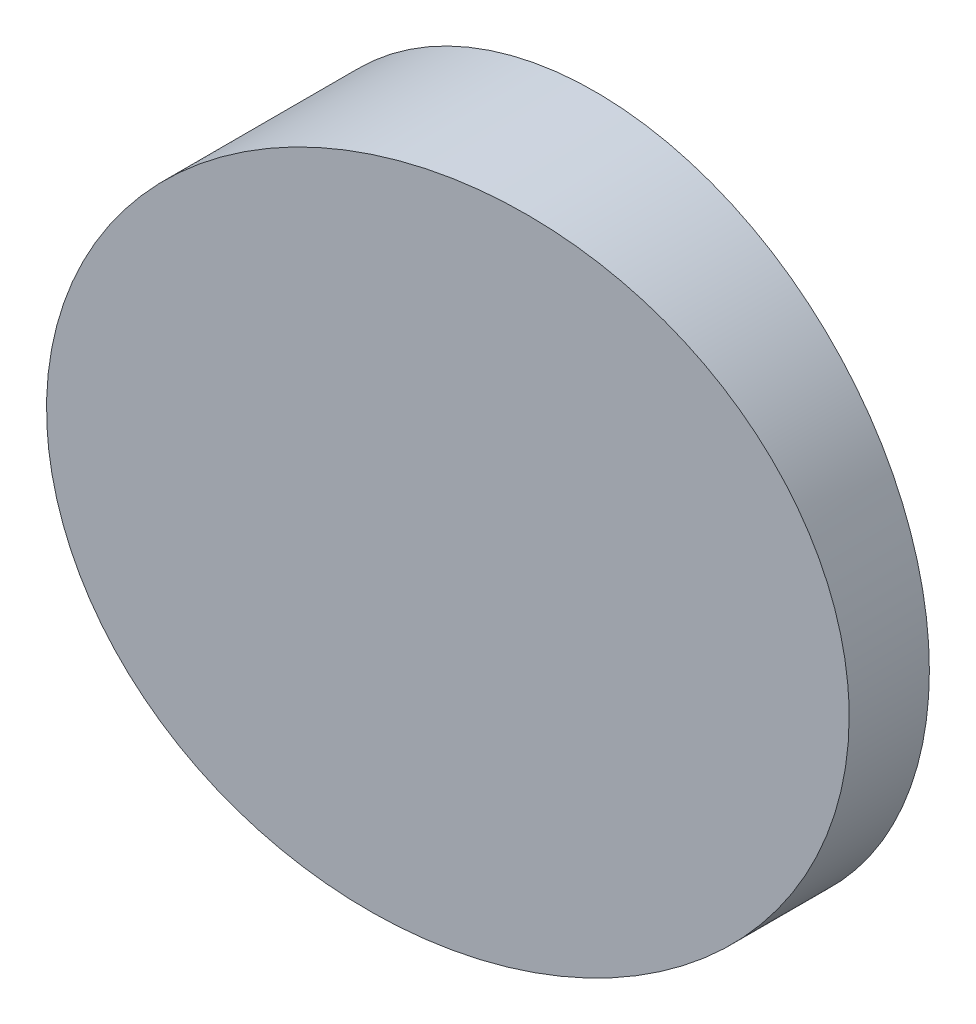
from build123d import *

# Parameters (mm, degrees)
SKETCH_1_R          = 12.5
EXTRUDE_1_DEPTH     = 10
CUT_EXTRUDE_1_DEPTH = 25


with BuildPart() as part:
    # 草图1 → 凸台-拉伸1 (new body)
    with BuildSketch(Plane.XY):
        Circle(SKETCH_1_R)
    extrude(amount=EXTRUDE_1_DEPTH)

    # 草图2 → 切除-拉伸1 (cut, symmetric)
    with BuildSketch(Plane(origin=(0, 0, 0), x_dir=(1, 0, 0), z_dir=(0, 1, 0))):
        Polygon((12.5, -3), (-16.072220308, -8.735227052), (-16.072220308, -19.673060042), (18.336610774, -19.673060042), (18.336610774, -3), align=None)
    extrude(amount=CUT_EXTRUDE_1_DEPTH, both=True, mode=Mode.SUBTRACT)


solid = part.part
